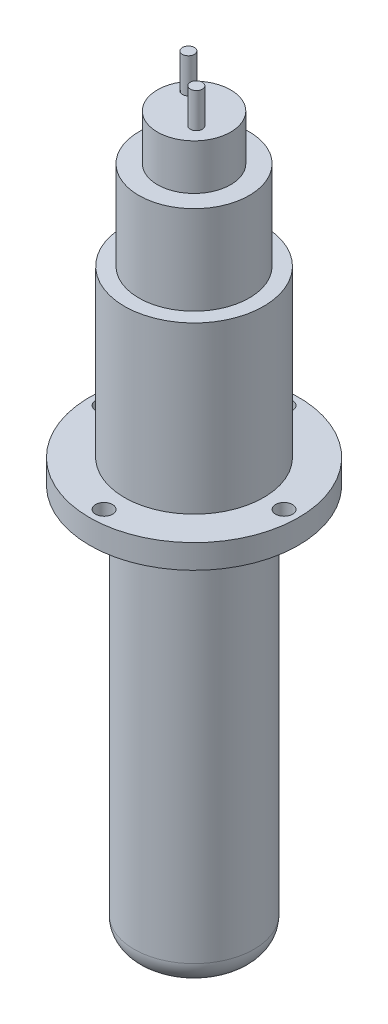
from build123d import *

# Parameters (mm, degrees)
SKETCH1_R           = 22.098
BOSS_EXTRUDE1_DEPTH = 5.08
SKETCH2_R           = 14.732
BOSS_EXTRUDE2_DEPTH = 35.052
SKETCH3_R           = 11.684
BOSS_EXTRUDE3_DEPTH = 18.796
SKETCH4_R           = 7.747
BOSS_EXTRUDE4_DEPTH = 9.652
SKETCH5_R           = 1.27
BOSS_EXTRUDE5_DEPTH = 7.366
SKETCH6_R           = 1.7907
CUT_EXTRUDE1_DEPTH  = 7.366
CIRPATTERN1_COUNT   = 4
SKETCH7_R           = 12.7
BOSS_EXTRUDE6_DEPTH = 83.82
FILLET1_R           = 5.08


with BuildPart() as part:
    # Sketch1 → Boss-Extrude1 (new body)
    with BuildSketch(Plane(origin=(0, 0, 0), x_dir=(1, 0, 0), z_dir=(0, 1, 0))):
        Circle(SKETCH1_R)
    extrude(amount=BOSS_EXTRUDE1_DEPTH)

    # Sketch2 → Boss-Extrude2 (add)
    with BuildSketch(Plane(origin=(0, 5.08, 0), x_dir=(1, 0, 0), z_dir=(0, 1, 0))):
        Circle(SKETCH2_R)
    extrude(amount=BOSS_EXTRUDE2_DEPTH)

    # Sketch3 → Boss-Extrude3 (add)
    with BuildSketch(Plane(origin=(0, 40.132, 0), x_dir=(1, 0, 0), z_dir=(0, 1, 0))):
        Circle(SKETCH3_R)
    extrude(amount=BOSS_EXTRUDE3_DEPTH)

    # Sketch4 → Boss-Extrude4 (add)
    with BuildSketch(Plane(origin=(0, 58.928, 0), x_dir=(1, 0, 0), z_dir=(0, 1, 0))):
        Circle(SKETCH4_R)
    extrude(amount=BOSS_EXTRUDE4_DEPTH)

    # Sketch5 → Boss-Extrude5 (add)
    with BuildSketch(Plane(origin=(0, 68.58, 0), x_dir=(1, 0, 0), z_dir=(0, 1, 0))):
        with Locations((-4.243406318, 3.044398822)):
            Circle(SKETCH5_R)
        with Locations((2.970026773, -2.481757502)):
            Circle(SKETCH5_R)
    extrude(amount=BOSS_EXTRUDE5_DEPTH)

    # Sketch6 → Cut-Extrude1 (cut)
    with BuildSketch(Plane(origin=(0, 5.08, 0), x_dir=(1, 0, 0), z_dir=(0, 1, 0))):
        with Locations((0, 19.05)):
            Circle(SKETCH6_R)
    cut_extrude1 = extrude(amount=-CUT_EXTRUDE1_DEPTH, mode=Mode.SUBTRACT)

    # CirPattern1: Cut-Extrude1 ×4 about axis
    cirpattern1_axis = Axis((0, 0, 0), (0, 1, 0))
    for i in range(1, CIRPATTERN1_COUNT):
        add(cut_extrude1.rotate(cirpattern1_axis, i * 360 / CIRPATTERN1_COUNT), mode=Mode.SUBTRACT)

    # Sketch7 → Boss-Extrude6 (add)
    with BuildSketch(Plane(origin=(0, 0, 0), x_dir=(-1, 0, 0), z_dir=(0, -1, 0))):
        Circle(SKETCH7_R)
    extrude(amount=BOSS_EXTRUDE6_DEPTH)

    # Fillet1
    fillet1_edges = [part.edges().sort_by_distance(p)[0] for p in [
        (12.7, -83.82, 0),
    ]]
    fillet(fillet1_edges, radius=FILLET1_R)


solid = part.part
